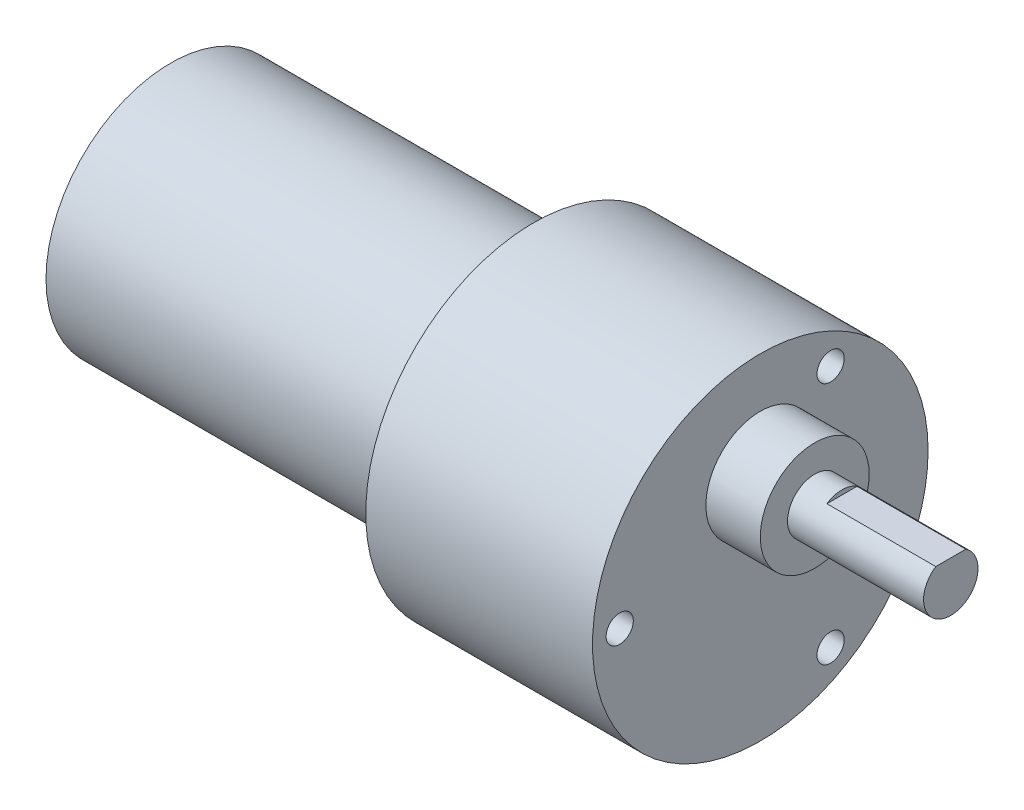
from build123d import *

# Parameters (mm, degrees)
SKETCH_1_R          = 13.75
EXTRUDE_1_DEPTH     = 20
SKETCH_2_R          = 5.1
EXTRUDE_2_DEPTH     = 3
SKETCH_3_R          = 18.5
EXTRUDE_3_DEPTH     = 25
SKETCH_4_R          = 6
EXTRUDE_4_DEPTH     = 6
SKETCH_5_R          = 3
EXTRUDE_5_DEPTH     = 15
CUT_EXTRUDE_1_DEPTH = 12
SKETCH_7_R          = 1.5
CUT_EXTRUDE_2_DEPTH = 3
CHAMFER_1_SIZE      = 2


with BuildPart() as part:
    # ｽｹｯﾁ1 → ﾎﾞｽ - 押し出し1 (new body, symmetric)
    with BuildSketch(Plane(origin=(0, 0, 0), x_dir=(0, 0, -1), z_dir=(1, 0, 0))):
        Circle(SKETCH_1_R)
    extrude(amount=EXTRUDE_1_DEPTH, both=True)

    # ｽｹｯﾁ2 → ﾎﾞｽ - 押し出し2 (add)
    with BuildSketch(Plane.ZY.offset(20)):
        Circle(SKETCH_2_R)
    extrude(amount=EXTRUDE_2_DEPTH)

    # ｽｹｯﾁ3 → ﾎﾞｽ - 押し出し3 (add)
    with BuildSketch(Plane(origin=(20, 0, 0), x_dir=(0, 0, -1), z_dir=(1, 0, 0))):
        Circle(SKETCH_3_R)
    extrude(amount=EXTRUDE_3_DEPTH)

    # ｽｹｯﾁ4 → ﾎﾞｽ - 押し出し4 (add)
    with BuildSketch(Plane(origin=(45, 0, 0), x_dir=(0, 0, -1), z_dir=(1, 0, 0))):
        with Locations((0, 7)):
            Circle(SKETCH_4_R)
    extrude(amount=EXTRUDE_4_DEPTH)

    # ｽｹｯﾁ5 → ﾎﾞｽ - 押し出し5 (add)
    with BuildSketch(Plane(origin=(51, 0, 0), x_dir=(0, 0, -1), z_dir=(1, 0, 0))):
        with Locations((0, 7)):
            Circle(SKETCH_5_R)
    extrude(amount=EXTRUDE_5_DEPTH)

    # ｽｹｯﾁ6 → ｶｯﾄ - 押し出し1 (cut)
    with BuildSketch(Plane(origin=(66, 0, 0), x_dir=(0, 0, -1), z_dir=(1, 0, 0))):
        Polygon((-80.661429966, 9.5), (-1.658312395, 9.5), (1.658312395, 9.5), (80.661429966, 9.5), (80.661429966, 167.506235142), (-80.661429966, 167.506235142), align=None)
    extrude(amount=-CUT_EXTRUDE_1_DEPTH, mode=Mode.SUBTRACT)

    # ｽｹｯﾁ7 → ｶｯﾄ - 押し出し2 (cut)
    with BuildSketch(Plane(origin=(45, 0, 0), x_dir=(0, 0, -1), z_dir=(1, 0, 0))):
        with Locations((-15.5, 0)):
            Circle(SKETCH_7_R)
        with Locations((7.75, 13.423393759)):
            Circle(SKETCH_7_R)
        with Locations((7.75, -13.423393759)):
            Circle(SKETCH_7_R)
    extrude(amount=-CUT_EXTRUDE_2_DEPTH, mode=Mode.SUBTRACT)

    # 面取り1
    chamfer_1_edges = [part.edges().sort_by_distance(p)[0] for p in [
        (20, 0, 13.75),
    ]]
    chamfer(chamfer_1_edges, length=CHAMFER_1_SIZE)


solid = part.part
